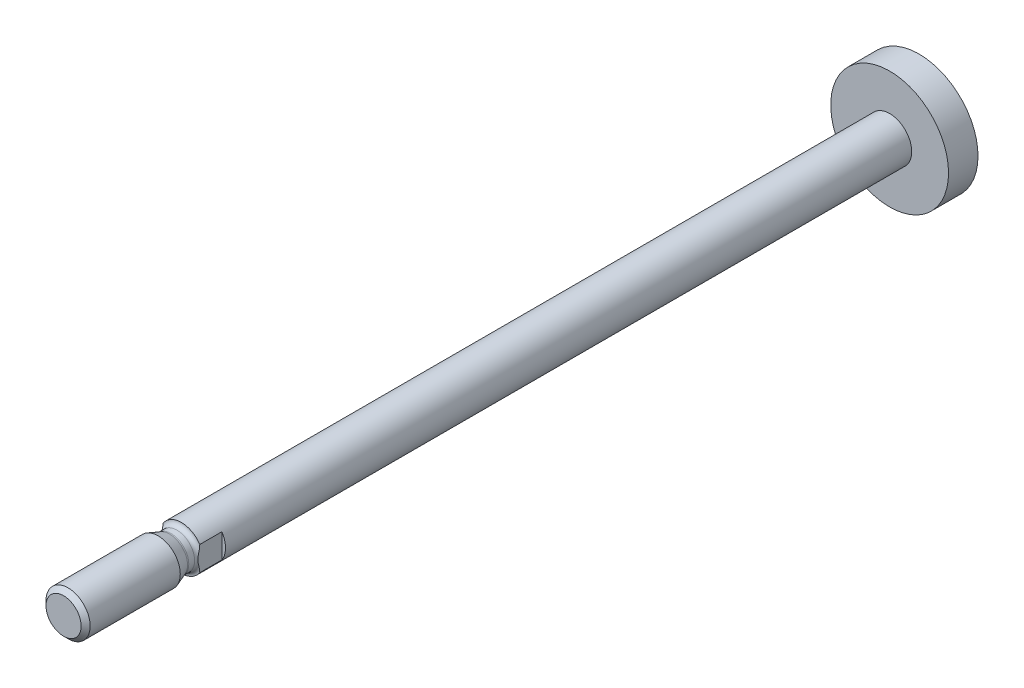
from build123d import *

# Parameters (mm, degrees)
CUT_EXTRUDE1_DEPTH = 4


with BuildPart() as part:
    # Sketch1 → Revolve1 (revolve)
    with BuildSketch(Plane(origin=(0, 0, 0), x_dir=(0, 0, -1), z_dir=(1, 0, 0))):
        Polygon((-5, 0), (-5, 3), (91.2, 3), (91.2, 8), (95.2, 8), (95.2, 0), align=None)
    revolve(axis=Axis((0, 0, -95.2), (0, 0, 1)))

    # Sketch2 → Revolve2 (revolve)
    with BuildSketch(Plane(origin=(0, 0, 0), x_dir=(0, 0, -1), z_dir=(1, 0, 0))):
        with BuildLine():
            Line((-21, 0), (-21, 2.3865))
            Line((-21, 2.3865), (-20.3865, 3))
            Line((-20.3865, 3), (-8.148486452, 3))
            Line((-8.148486452, 3), (-6.599415898, 2.436184428))
            ThreePointArc((-6.599415898, 2.436184428), (-6.498392718, 2.409115348), (-6.394203812, 2.4))
            Line((-6.394203812, 2.4), (-5.6, 2.4))
            ThreePointArc((-5.6, 2.4), (-5.175735931, 2.575735931), (-5, 3))
            Line((-5, 3), (-4, 3))
            Line((-4, 3), (-4, 0))
            Line((-4, 0), (-21, 0))
        make_face()
    revolve(axis=Axis((0, 0, 4), (0, 0, 1)))

    # Sketch3 → Cut-Extrude1 (cut)
    with BuildSketch(Plane.XY.offset(2)):
        Polygon((-5, 10), (-5, -5), (-2.5, -5), (-2.5, 5), (2.5, 5), (2.5, -5), (5, -5), (5, 10), align=None)
    extrude(amount=CUT_EXTRUDE1_DEPTH, mode=Mode.SUBTRACT)


solid = part.part
